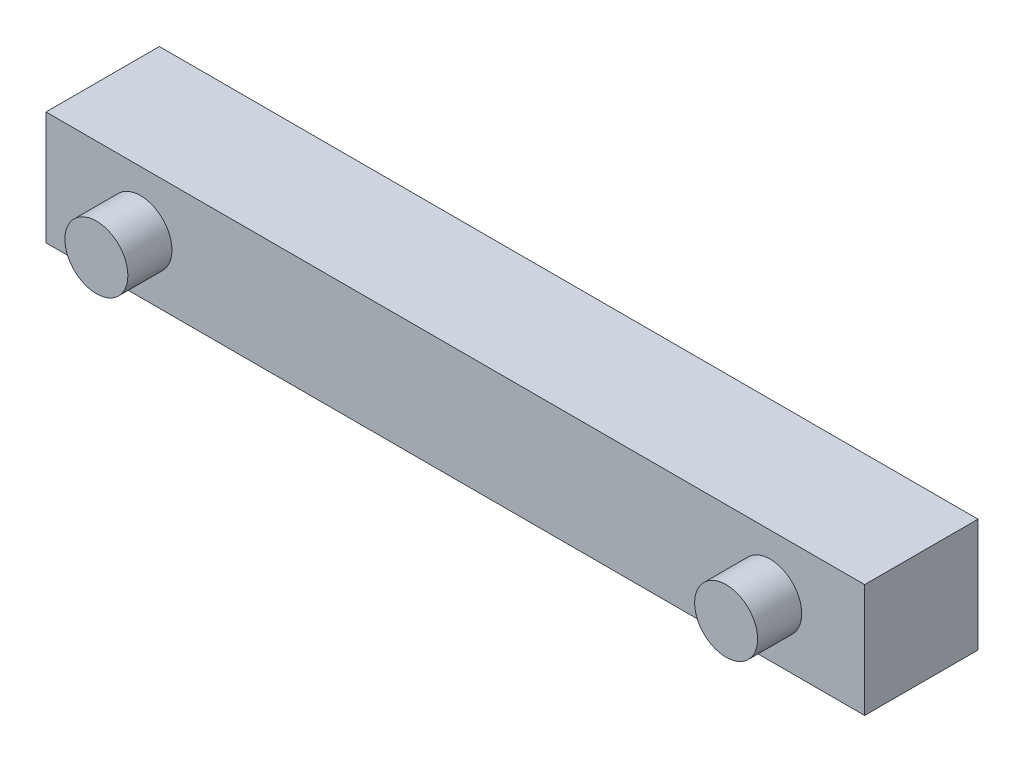
from build123d import *

# Parameters (mm, degrees)
SKETCH1_W           = 65
SKETCH1_H           = 9
BOSS_EXTRUDE4_DEPTH = 9
SKETCH5_R           = 2.5
BOSS_EXTRUDE5_DEPTH = 3.5


with BuildPart() as part:
    # Sketch1 → Boss-Extrude4 (new body)
    with BuildSketch(Plane.XY):
        with Locations((32.5, 4.5)):
            Rectangle(SKETCH1_W, SKETCH1_H)
    extrude(amount=BOSS_EXTRUDE4_DEPTH)

    # Sketch5 → Boss-Extrude5 (add)
    with BuildSketch(Plane.XY.offset(9)):
        with Locations(Location((7.5, 4.5, 0), (0, 0, 180))):  # turned: the seam where the file's is
            Circle(SKETCH5_R)
        with Locations(Location((57.5, 4.5, 0), (0, 0, 180))):  # turned: the seam where the file's is
            Circle(SKETCH5_R)
    extrude(amount=BOSS_EXTRUDE5_DEPTH)


solid = part.part
